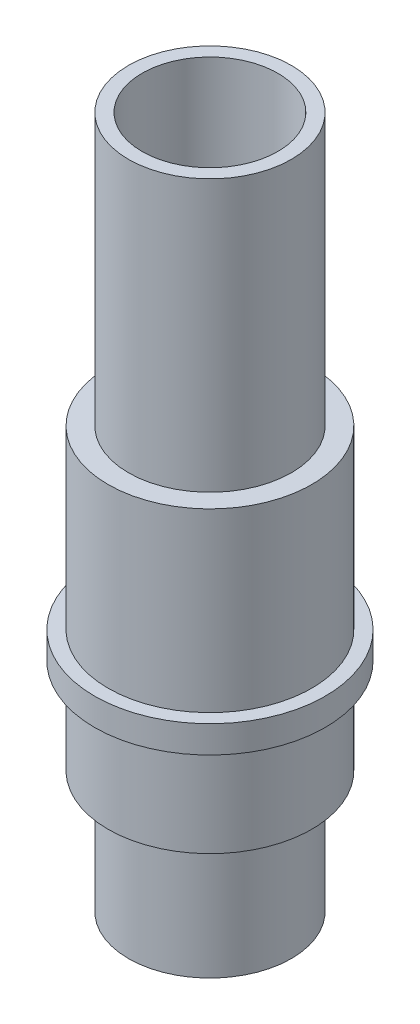
from build123d import *

# Parameters (mm, degrees)
ESQUISSE1_R        = 6
ESQUISSE1_R_2      = 5
BOSS_EXTRU_1_DEPTH = 9
ESQUISSE2_R        = 7.5
ESQUISSE2_R_2      = 5
BOSS_EXTRU_2_DEPTH = 7
ESQUISSE3_R        = 8.5
ESQUISSE3_R_2      = 5
BOSS_EXTRU_3_DEPTH = 2
ESQUISSE4_R        = 7.5
ESQUISSE4_R_2      = 5
BOSS_EXTRU_4_DEPTH = 13
ESQUISSE5_R        = 6
ESQUISSE5_R_2      = 5
BOSS_EXTRU_5_DEPTH = 20


with BuildPart() as part:
    # Esquisse1 → Boss.-Extru.1 (new body)
    with BuildSketch(Plane(origin=(0, 0, 0), x_dir=(1, 0, 0), z_dir=(0, 1, 0))):
        Circle(ESQUISSE1_R)
        Circle(ESQUISSE1_R_2, mode=Mode.SUBTRACT)
    extrude(amount=BOSS_EXTRU_1_DEPTH)

    # Esquisse2 → Boss.-Extru.2 (add)
    with BuildSketch(Plane(origin=(0, 9, 0), x_dir=(1, 0, 0), z_dir=(0, 1, 0))):
        Circle(ESQUISSE2_R)
        Circle(ESQUISSE2_R_2, mode=Mode.SUBTRACT)
    extrude(amount=BOSS_EXTRU_2_DEPTH)

    # Esquisse3 → Boss.-Extru.3 (add)
    with BuildSketch(Plane(origin=(0, 16, 0), x_dir=(1, 0, 0), z_dir=(0, 1, 0))):
        Circle(ESQUISSE3_R)
        Circle(ESQUISSE3_R_2, mode=Mode.SUBTRACT)
    extrude(amount=BOSS_EXTRU_3_DEPTH)

    # Esquisse4 → Boss.-Extru.4 (add)
    with BuildSketch(Plane(origin=(0, 18, 0), x_dir=(1, 0, 0), z_dir=(0, 1, 0))):
        Circle(ESQUISSE4_R)
        Circle(ESQUISSE4_R_2, mode=Mode.SUBTRACT)
    extrude(amount=BOSS_EXTRU_4_DEPTH)

    # Esquisse5 → Boss.-Extru.5 (add)
    with BuildSketch(Plane(origin=(0, 31, 0), x_dir=(1, 0, 0), z_dir=(0, 1, 0))):
        Circle(ESQUISSE5_R)
        Circle(ESQUISSE5_R_2, mode=Mode.SUBTRACT)
    extrude(amount=BOSS_EXTRU_5_DEPTH)


solid = part.part
